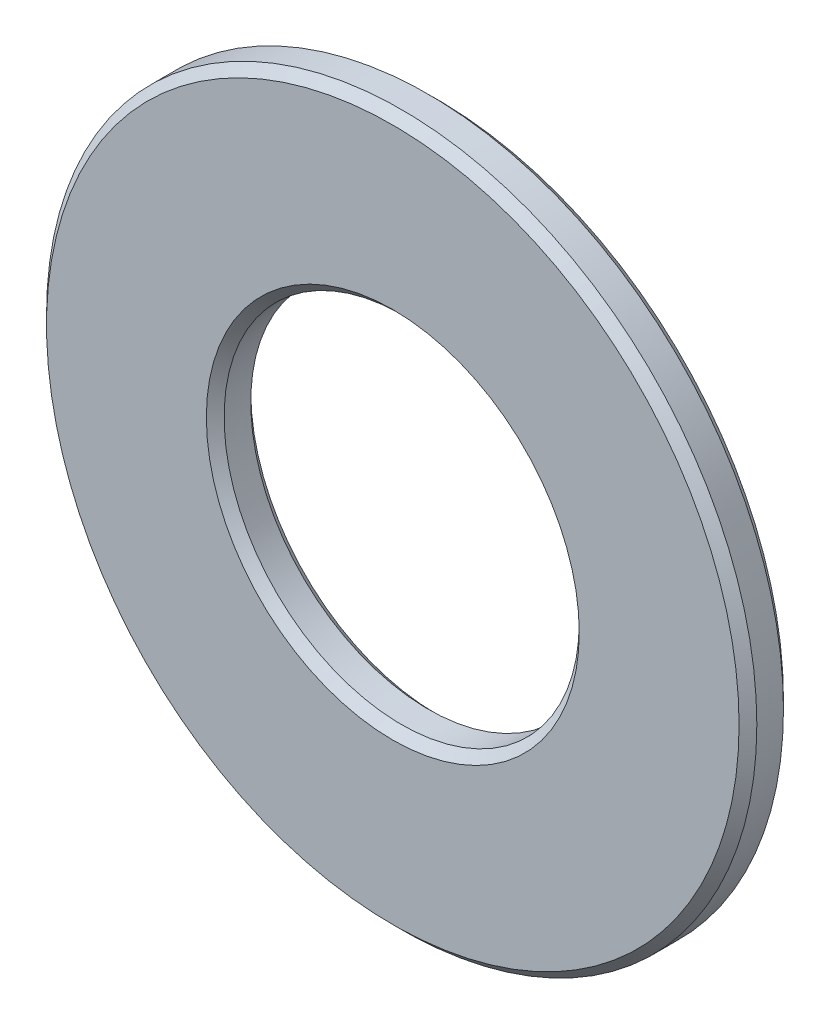
from build123d import *

# Parameters (mm, degrees)
SKETCH_1_R      = 4
SKETCH_1_R_2    = 2
EXTRUDE_1_DEPTH = 0.5
CHAMFER_1_SIZE  = 0.1


with BuildPart() as part:
    # Эскиз1 → Бобышка-Вытянуть1 (new body)
    with BuildSketch(Plane.XY):
        Circle(SKETCH_1_R)
        Circle(SKETCH_1_R_2, mode=Mode.SUBTRACT)
    extrude(amount=EXTRUDE_1_DEPTH)

    # Фаска1
    chamfer_1_edges = [part.edges().sort_by_distance(p)[0] for p in [
        (-4, 0, 0),
        (-4, 0, 0.5),
        (-2, 0, 0),
        (-2, 0, 0.5),
    ]]
    chamfer(chamfer_1_edges, length=CHAMFER_1_SIZE)


solid = part.part
